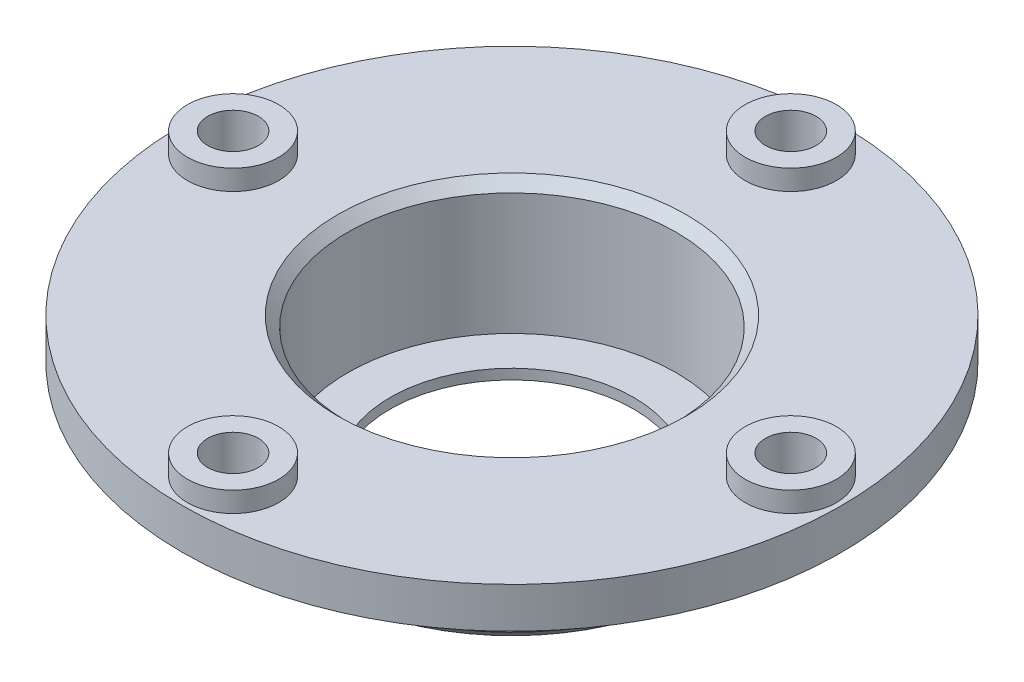
from build123d import *

# Parameters (mm, degrees)
SKETCH1_R           = 19.9
SKETCH1_R_2         = 16.2
BOSS_EXTRUDE1_DEPTH = 9
SKETCH2_R           = 22
SKETCH2_R_2         = 16.2
BOSS_EXTRUDE2_DEPTH = 1
SKETCH3_R           = 32.5
SKETCH3_R_2         = 16.2
BOSS_EXTRUDE3_DEPTH = 1
SKETCH6_R           = 32.5
SKETCH6_R_2         = 2.5
SKETCH6_R_3         = 16.2
BOSS_EXTRUDE6_DEPTH = 3
SKETCH7_R           = 4.5
SKETCH7_R_2         = 2.5
BOSS_EXTRUDE7_DEPTH = 2
SKETCH8_R           = 16.2
SKETCH8_R_2         = 12
BOSS_EXTRUDE8_DEPTH = 1
SKETCH9_R           = 2.5
CUT_EXTRUDE1_DEPTH  = 10
CHAMFER1_SIZE       = 1
CHAMFER2_SIZE       = 1


with BuildPart() as part:
    # Sketch1 → Boss-Extrude1 (new body)
    with BuildSketch(Plane(origin=(0, 0, 0), x_dir=(1, 0, 0), z_dir=(0, 1, 0))):
        Circle(SKETCH1_R)
        Circle(SKETCH1_R_2, mode=Mode.SUBTRACT)
    extrude(amount=BOSS_EXTRUDE1_DEPTH)

    # Sketch2 → Boss-Extrude2 (add)
    with BuildSketch(Plane(origin=(0, 9, 0), x_dir=(1, 0, 0), z_dir=(0, 1, 0))):
        Circle(SKETCH2_R)
        Circle(SKETCH2_R_2, mode=Mode.SUBTRACT)
    extrude(amount=BOSS_EXTRUDE2_DEPTH)

    # Sketch3 → Boss-Extrude3 (add)
    with BuildSketch(Plane(origin=(0, 10, 0), x_dir=(1, 0, 0), z_dir=(0, 1, 0))):
        Circle(SKETCH3_R)
        Circle(SKETCH3_R_2, mode=Mode.SUBTRACT)
    extrude(amount=BOSS_EXTRUDE3_DEPTH)

    # Sketch6 → Boss-Extrude6 (add)
    with BuildSketch(Plane(origin=(0, 11, 0), x_dir=(1, 0, 0), z_dir=(0, 1, 0))):
        Circle(SKETCH6_R)
        with Locations((0, 27.5)):
            Circle(SKETCH6_R_2, mode=Mode.SUBTRACT)
        with Locations((27.5, 0)):
            Circle(SKETCH6_R_2, mode=Mode.SUBTRACT)
        with Locations((0, -27.5)):
            Circle(SKETCH6_R_2, mode=Mode.SUBTRACT)
        with Locations((-27.5, 0)):
            Circle(SKETCH6_R_2, mode=Mode.SUBTRACT)
        Circle(SKETCH6_R_3, mode=Mode.SUBTRACT)
    extrude(amount=BOSS_EXTRUDE6_DEPTH)

    # Sketch7 → Boss-Extrude7 (add)
    with BuildSketch(Plane(origin=(0, 14, 0), x_dir=(1, 0, 0), z_dir=(0, 1, 0))):
        with Locations((0, -27.5)):
            Circle(SKETCH7_R)
        with Locations((0, -27.5)):
            Circle(SKETCH7_R_2, mode=Mode.SUBTRACT)
        with Locations((0, 27.5)):
            Circle(SKETCH7_R)
        with Locations((0, 27.5)):
            Circle(SKETCH7_R_2, mode=Mode.SUBTRACT)
        with Locations((27.5, 0)):
            Circle(SKETCH7_R)
        with Locations((27.5, 0)):
            Circle(SKETCH7_R_2, mode=Mode.SUBTRACT)
        with Locations((-27.5, 0)):
            Circle(SKETCH7_R)
        with Locations((-27.5, 0)):
            Circle(SKETCH7_R_2, mode=Mode.SUBTRACT)
    extrude(amount=BOSS_EXTRUDE7_DEPTH)

    # Sketch8 → Boss-Extrude8 (add)
    with BuildSketch(Plane(origin=(0, 0, 0), x_dir=(-1, 0, 0), z_dir=(0, -1, 0))):
        Circle(SKETCH8_R)
        Circle(SKETCH8_R_2, mode=Mode.SUBTRACT)
    extrude(amount=-BOSS_EXTRUDE8_DEPTH)

    # Sketch9 → Cut-Extrude1 (cut)
    with BuildSketch(Plane(origin=(0, 11, 0), x_dir=(1, 0, 0), z_dir=(0, 1, 0))):
        with Locations((0, -27.5)):
            Circle(SKETCH9_R)
        with Locations((27.5, 0)):
            Circle(SKETCH9_R)
        with Locations((0, 27.5)):
            Circle(SKETCH9_R)
        with Locations((-27.5, 0)):
            Circle(SKETCH9_R)
    extrude(amount=-CUT_EXTRUDE1_DEPTH, mode=Mode.SUBTRACT)

    # Chamfer1
    chamfer1_edges = [part.edges().sort_by_distance(p)[0] for p in [
        (-16.2, 14, 0),
    ]]
    chamfer(chamfer1_edges, length=CHAMFER1_SIZE)

    # Chamfer2
    chamfer2_edges = [part.edges().sort_by_distance(p)[0] for p in [
        (-19.9, 0, 0),
    ]]
    chamfer(chamfer2_edges, length=CHAMFER2_SIZE)


solid = part.part
